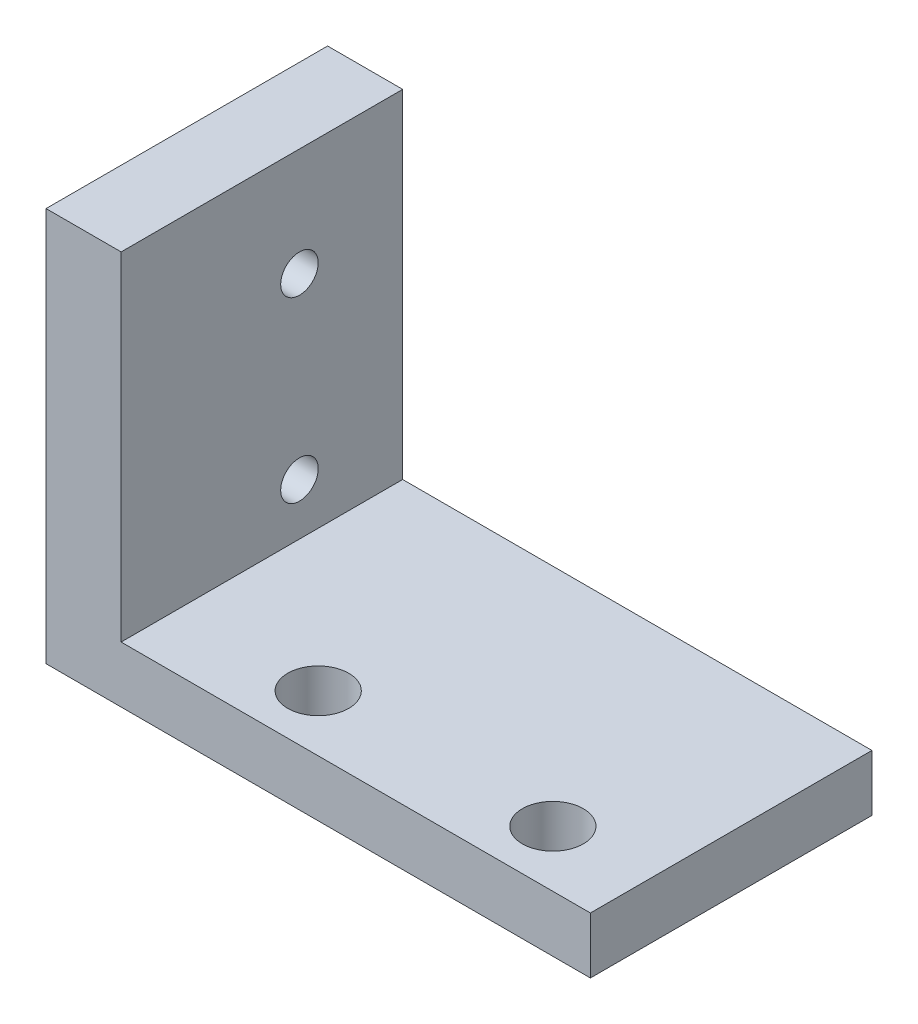
from build123d import *

# Parameters (mm, degrees)
SKETCH1_W           = 29
SKETCH1_H           = 15
BOSS_EXTRUDE1_DEPTH = 3
SKETCH3_R           = 1.625
CUT_EXTRUDE2_DEPTH  = 4
SKETCH4_W           = 4
SKETCH4_H           = 15
BOSS_EXTRUDE2_DEPTH = 18
SKETCH5_R           = 1
CUT_EXTRUDE3_DEPTH  = 13


with BuildPart() as part:
    # Sketch1 → Boss-Extrude1 (new body)
    with BuildSketch(Plane(origin=(0, 0, 0), x_dir=(1, 0, 0), z_dir=(0, 1, 0))):
        Rectangle(SKETCH1_W, SKETCH1_H)
    extrude(amount=BOSS_EXTRUDE1_DEPTH)

    # Sketch3 → Cut-Extrude2 (cut, through all)
    with BuildSketch(Plane(origin=(0, 3, 0), x_dir=(1, 0, 0), z_dir=(0, 1, 0))):
        with Locations((-3, -4.5)):
            Circle(SKETCH3_R)
        with Locations((9.5, -4.5)):
            Circle(SKETCH3_R)
    extrude(amount=-CUT_EXTRUDE2_DEPTH, mode=Mode.SUBTRACT)

    # Sketch4 → Boss-Extrude2 (add)
    with BuildSketch(Plane(origin=(0, 3, 0), x_dir=(1, 0, 0), z_dir=(0, 1, 0))):
        with Locations((-12.5, 0)):
            Rectangle(SKETCH4_W, SKETCH4_H)
    extrude(amount=BOSS_EXTRUDE2_DEPTH)

    # Sketch5 → Cut-Extrude3 (cut)
    with BuildSketch(Plane.ZY.offset(14.5)):
        with Locations((-2, 15.25)):
            Circle(SKETCH5_R)
        with Locations((-2, 5.75)):
            Circle(SKETCH5_R)
    extrude(amount=-CUT_EXTRUDE3_DEPTH, mode=Mode.SUBTRACT)


solid = part.part
